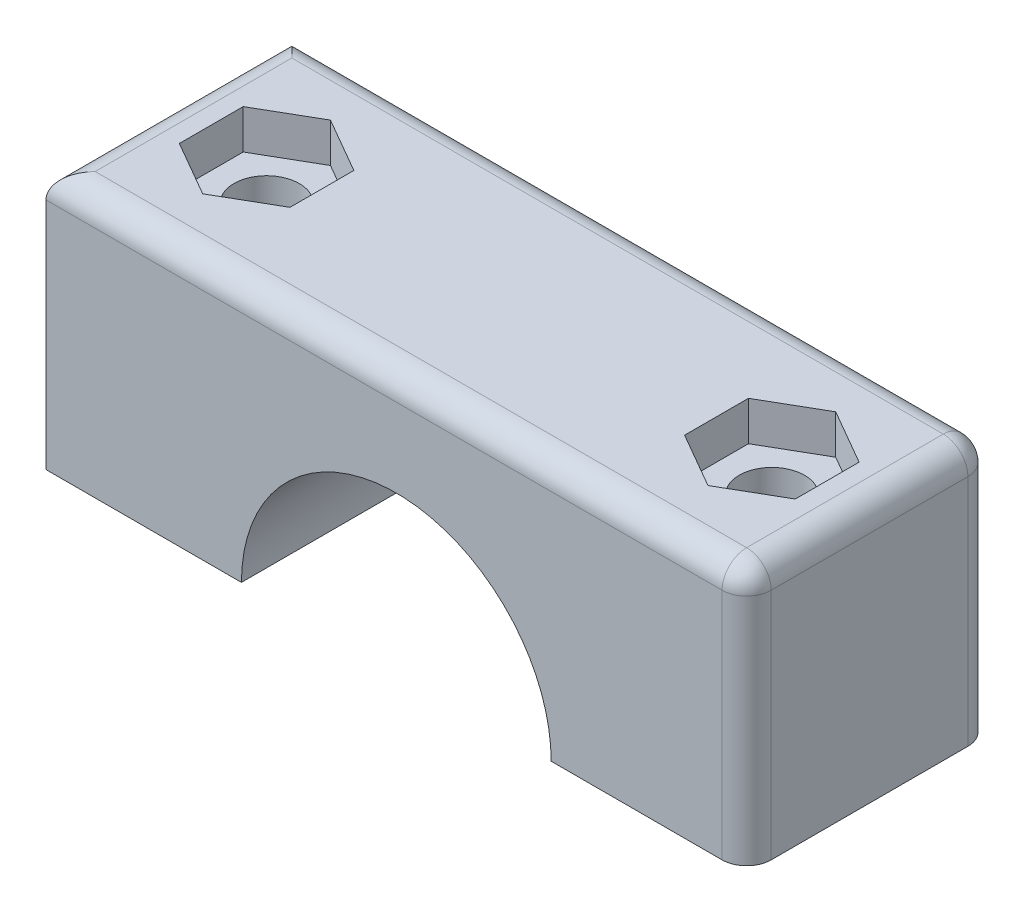
from build123d import *

# Parameters (mm, degrees)
SKETCH3_W           = 72.39
SKETCH3_H           = 26.67
BOSS_EXTRUDE1_DEPTH = 12.7
SKETCH4_R           = 16.002
CUT_EXTRUDE1_DEPTH  = 26.4
SKETCH7_R           = 3.3782
CUT_EXTRUDE2_DEPTH  = 15.875
FILLET1_R           = 2.54
CUT_EXTRUDE3_DEPTH  = 4.064


with BuildPart() as part:
    # Sketch3 → Boss-Extrude1 (new body, symmetric)
    with BuildSketch(Plane.XY):
        Rectangle(SKETCH3_W, SKETCH3_H)
    extrude(amount=BOSS_EXTRUDE1_DEPTH, both=True)

    # Sketch4 → Cut-Extrude1 (cut, through all)
    with BuildSketch(Plane.XY.offset(12.7)):
        with Locations((0, -13.335)):
            Circle(SKETCH4_R)
    extrude(amount=-CUT_EXTRUDE1_DEPTH, mode=Mode.SUBTRACT)

    # Sketch7 → Cut-Extrude2 (cut, symmetric)
    with BuildSketch(Plane(origin=(0, 0, 0), x_dir=(1, 0, 0), z_dir=(0, 1, 0))):
        with Locations((-26.101920205, 0)):
            Circle(SKETCH7_R)
    cut_extrude2 = extrude(amount=CUT_EXTRUDE2_DEPTH, both=True, mode=Mode.SUBTRACT)

    # Mirror1: Cut-Extrude2 across plane
    add(cut_extrude2.mirror(Plane(origin=(0, 0, 0), x_dir=(0, 0, 1), z_dir=(1, 0, 0))), mode=Mode.SUBTRACT)

    # Fillet1
    fillet1_edges = [part.edges().sort_by_distance(p)[0] for p in [
        (36.195, 0, 12.7),
        (0, 13.335, -12.7),
        (36.195, 0, -12.7),
        (-36.195, 13.335, 0),
        (36.195, 13.335, 0),
        (0, 13.335, 12.7),
    ]]
    fillet(fillet1_edges, radius=FILLET1_R)

    # Sketch8 → Cut-Extrude3 (cut)
    with BuildSketch(Plane(origin=(0, 13.335, 0), x_dir=(1, 0, 0), z_dir=(0, 1, 0))):
        Polygon((-26.101920205, -6.599113577), (-20.386920205, -3.299556788), (-20.386920205, 3.299556788), (-26.101920205, 6.599113577), (-31.816920205, 3.299556788), (-31.816920205, -3.299556788), align=None)
    cut_extrude3 = extrude(amount=-CUT_EXTRUDE3_DEPTH, mode=Mode.SUBTRACT)

    # Mirror2: Cut-Extrude3 across plane
    add(cut_extrude3.mirror(Plane(origin=(0, 0, 0), x_dir=(0, 0, 1), z_dir=(1, 0, 0))), mode=Mode.SUBTRACT)


solid = part.part
